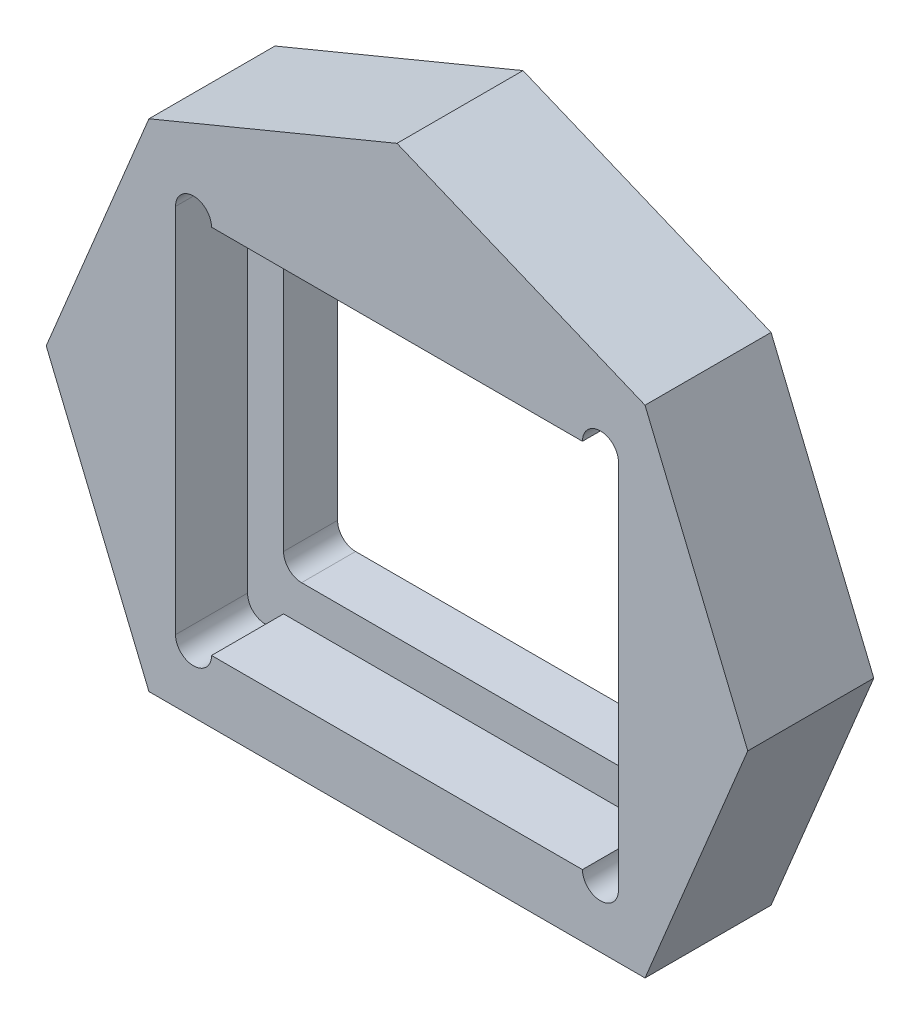
from build123d import *

# Parameters (mm, degrees)
BOSS_EXTRUDE1_DEPTH = 1.5
SKETCH2_W           = 12.3
SKETCH2_H           = 10.3
BOSS_EXTRUDE2_DEPTH = 2
CUT_EXTRUDE1_DEPTH  = 2
CUT_EXTRUDE2_REACH  = 5.5


with BuildPart() as part:
    # Sketch1 → Boss-Extrude1 (new body)
    with BuildSketch(Plane.XY):
        Polygon((6.888301783, 6.888301783), (0, 9.741529803), (-6.888301783, 6.888301783), (-9.741529803, 0), (-6.888301783, -6.888301783), (0, -9.741529803), (6.888301783, -6.888301783), (9.741529803, 0), align=None)
        with BuildLine():
            Line((-5.15, -3.65), (-5.15, 3.65))
            ThreePointArc((-5.15, 3.65), (-5.003553391, 4.003553391), (-4.65, 4.15))
            Line((-4.65, 4.15), (4.65, 4.15))
            ThreePointArc((4.65, 4.15), (5.003553391, 4.003553391), (5.15, 3.65))
            Line((5.15, 3.65), (5.15, -3.65))
            ThreePointArc((5.15, -3.65), (5.003553391, -4.003553391), (4.65, -4.15))
            Line((4.65, -4.15), (-4.65, -4.15))
            ThreePointArc((-4.65, -4.15), (-5.003553391, -4.003553391), (-5.15, -3.65))
        make_face(mode=Mode.SUBTRACT)
    extrude(amount=BOSS_EXTRUDE1_DEPTH)

    # Sketch2 → Boss-Extrude2 (add)
    with BuildSketch(Plane.XY.offset(1.5)):
        Polygon((9.741529803, 0), (6.888301783, 6.888301783), (0, 9.741529803), (-6.888301783, 6.888301783), (-9.741529803, 0), (-6.888301783, -6.888301783), (0, -9.741529803), (6.888301783, -6.888301783), align=None)
        Rectangle(SKETCH2_W, SKETCH2_H, mode=Mode.SUBTRACT)
    extrude(amount=BOSS_EXTRUDE2_DEPTH)

    # Sketch3 → Cut-Extrude1 (cut)
    with BuildSketch(Plane.XY.offset(3.5)):
        with BuildLine():
            Line((-6.15, -5.15), (-6.15, 5.15))
            ThreePointArc((-6.15, 5.15), (-5.65, 5.65), (-5.15, 5.15))
            Line((-5.15, 5.15), (-5.15, -5.15))
            ThreePointArc((-5.15, -5.15), (-5.65, -5.65), (-6.15, -5.15))
        make_face()
        with BuildLine():
            Line((5.15, -5.15), (5.15, 5.15))
            ThreePointArc((5.15, 5.15), (5.65, 5.65), (6.15, 5.15))
            Line((6.15, 5.15), (6.15, -5.15))
            ThreePointArc((6.15, -5.15), (5.65, -5.65), (5.15, -5.15))
        make_face()
    extrude(amount=-CUT_EXTRUDE1_DEPTH, mode=Mode.SUBTRACT)

    # Sketch4 → Cut-Extrude2 (cut, up to next)
    with BuildSketch(Plane.XY.offset(3.5), mode=Mode.PRIVATE) as cut_extrude2_sk1:
        Polygon((-6.888301783, -6.888301783), (6.888301783, -6.888301783), (0, -9.741529803), align=None)
    cut_extrude2_tool1 = extrude(cut_extrude2_sk1.sketch, amount=-CUT_EXTRUDE2_REACH, mode=Mode.PRIVATE) & part.part
    add(cut_extrude2_tool1.solids().sort_by_distance((0, -7.839378, 3.5))[0], mode=Mode.SUBTRACT)


solid = part.part
